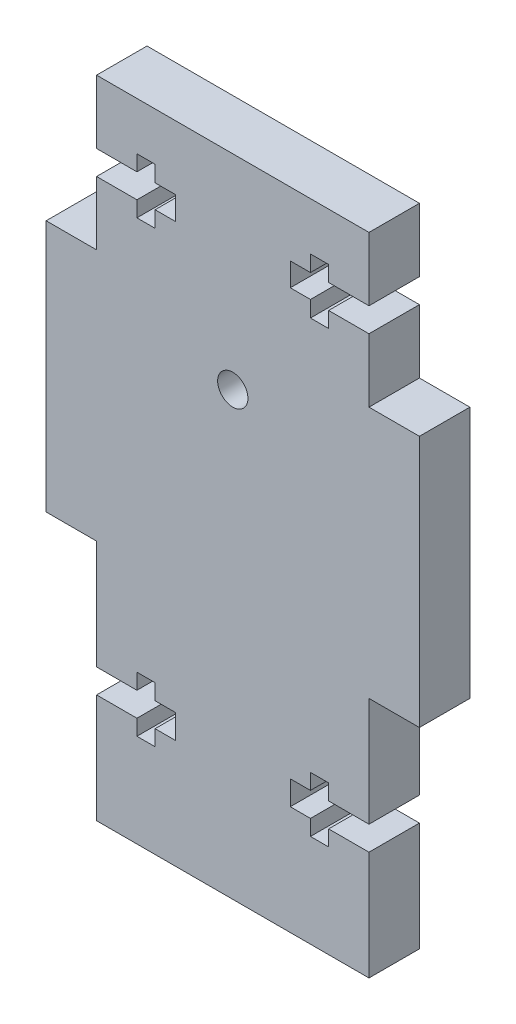
from build123d import *

# Parameters (mm, degrees)
SKETCH1_R           = 1.5
BOSS_EXTRUDE1_DEPTH = 5
CUT_EXTRUDE2_DEPTH  = 6


with BuildPart() as part:
    # Sketch1 → Boss-Extrude1 (new body)
    with BuildSketch(Plane.XY):
        Polygon((-13.5, 0), (13.5, 0), (13.5, 24), (18.5, 24), (18.5, 49), (13.5, 49), (13.5, 64), (-13.5, 64), (-13.5, 49), (-18.5, 49), (-18.5, 24), (-13.5, 24), align=None)
        with Locations((0, 43.75)):
            Circle(SKETCH1_R, mode=Mode.SUBTRACT)
    extrude(amount=BOSS_EXTRUDE1_DEPTH)

    # Sketch2 → Cut-Extrude2 (cut, through all)
    with BuildSketch(Plane.XY.offset(5)):
        Polygon((-13.5, 56.5), (-13.5, 57.7), (-9.5, 57.7), (-9.5, 59.25), (-7.7, 59.25), (-7.7, 57.654169795), (-5.7, 57.654169795), (-5.7, 55.345830205), (-7.7, 55.345830205), (-7.7, 53.75), (-9.5, 53.75), (-9.5, 55.3), (-13.5, 55.3), align=None)
        Polygon((13.5, 56.5), (13.5, 55.3), (9.5, 55.3), (9.5, 53.75), (7.7, 53.75), (7.7, 55.345830205), (5.7, 55.345830205), (5.7, 57.654169795), (7.7, 57.654169795), (7.7, 59.25), (9.5, 59.25), (9.5, 57.7), (13.5, 57.7), align=None)
        Polygon((-13.5, 10.8), (-13.5, 13.2), (-9.5, 13.2), (-9.5, 14.75), (-7.7, 14.75), (-7.7, 13.2), (-5.7, 13.2), (-5.7, 10.8), (-7.7, 10.8), (-7.7, 9.25), (-9.5, 9.25), (-9.5, 10.8), align=None)
        Polygon((13.5, 10.8), (9.5, 10.8), (9.5, 9.25), (7.7, 9.25), (7.7, 10.8), (5.7, 10.8), (5.7, 13.2), (7.7, 13.2), (7.7, 14.75), (9.5, 14.75), (9.5, 13.2), (13.5, 13.2), align=None)
    extrude(amount=-CUT_EXTRUDE2_DEPTH, mode=Mode.SUBTRACT)


solid = part.part
